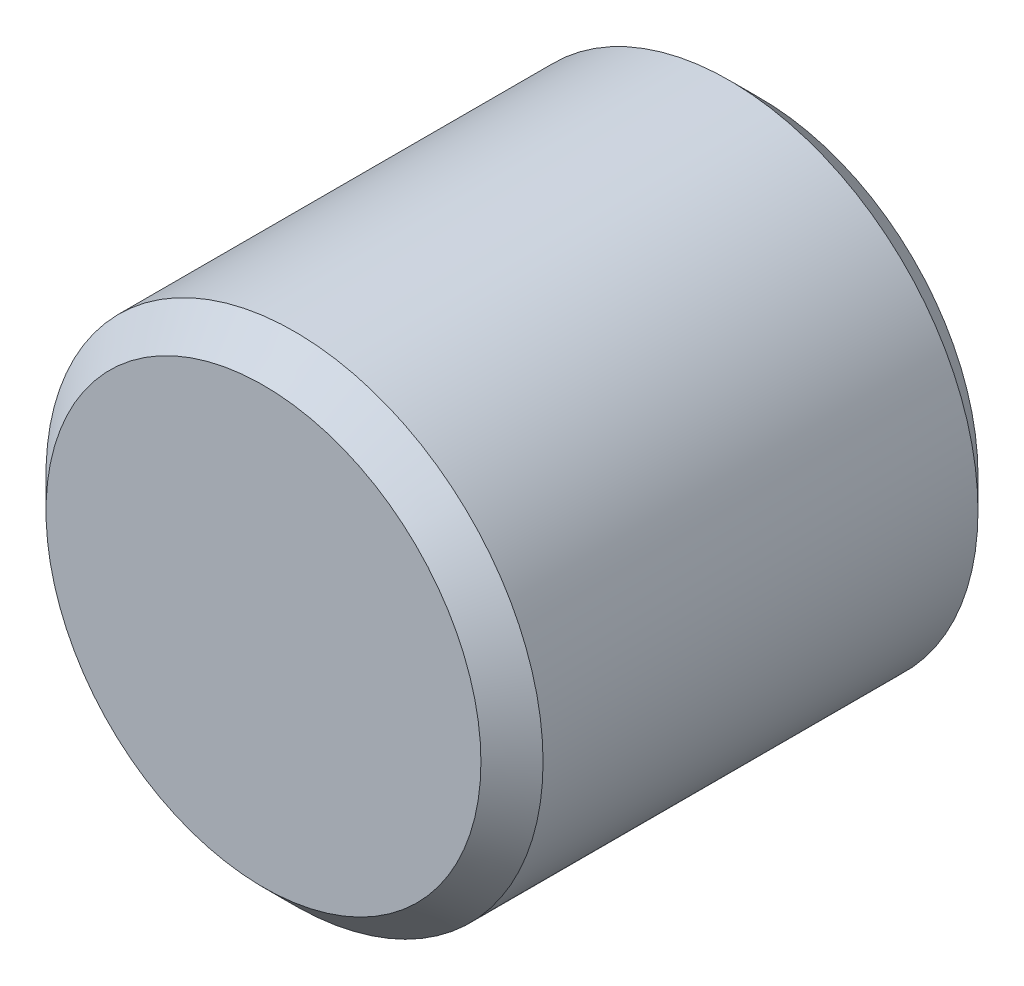
from build123d import *

# Parameters (mm, degrees)
SKETCH1_R           = 2
BOSS_EXTRUDE1_DEPTH = 4
CHAMFER1_SIZE       = 0.25


with BuildPart() as part:
    # Sketch1 → Boss-Extrude1 (new body)
    with BuildSketch(Plane.XY):
        Circle(SKETCH1_R)
    extrude(amount=BOSS_EXTRUDE1_DEPTH)

    # Chamfer1
    chamfer1_edges = [part.edges().sort_by_distance(p)[0] for p in [
        (-2, 0, 0),
        (-2, 0, 4),
    ]]
    chamfer(chamfer1_edges, length=CHAMFER1_SIZE)


solid = part.part
